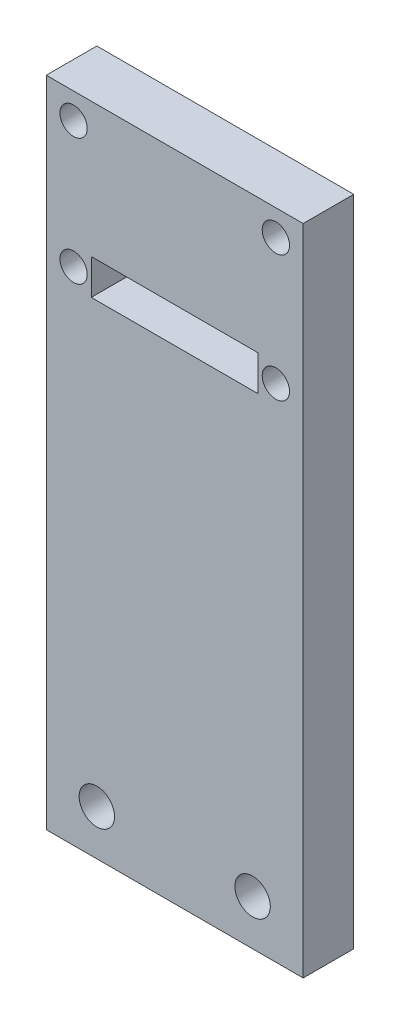
from build123d import *

# Parameters (mm, degrees)
SKETCH1_W           = 25.4
SKETCH1_H           = 64.6
BOSS_EXTRUDE1_DEPTH = 5
SKETCH2_R           = 1.35
SKETCH2_W           = 16.5
SKETCH2_H           = 3.5
CUT_EXTRUDE1_DEPTH  = 6
SKETCH3_R           = 1.75
CUT_EXTRUDE2_DEPTH  = 6


with BuildPart() as part:
    # Sketch1 → Boss-Extrude1 (new body)
    with BuildSketch(Plane.XY):
        with Locations((0, 122.3)):
            Rectangle(SKETCH1_W, SKETCH1_H)
    extrude(amount=-BOSS_EXTRUDE1_DEPTH)

    # Sketch2 → Cut-Extrude1 (cut, through all)
    with BuildSketch(Plane(origin=(0, 0, -5), x_dir=(-1, 0, 0), z_dir=(0, 0, -1))):
        with Locations((-10, 152.05)):
            Circle(SKETCH2_R)
        with Locations((10, 152.05)):
            Circle(SKETCH2_R)
        with Locations((-10, 139.55)):
            Circle(SKETCH2_R)
        with Locations((10, 139.55)):
            Circle(SKETCH2_R)
        with Locations((0, 139.55)):
            Rectangle(SKETCH2_W, SKETCH2_H)
    extrude(amount=-CUT_EXTRUDE1_DEPTH, mode=Mode.SUBTRACT)

    # Sketch3 → Cut-Extrude2 (cut, through all)
    with BuildSketch(Plane.XY):
        with Locations((-7.7, 94.48222968)):
            Circle(SKETCH3_R)
        with Locations((7.7, 94.48222968)):
            Circle(SKETCH3_R)
    extrude(amount=-CUT_EXTRUDE2_DEPTH, mode=Mode.SUBTRACT)


solid = part.part
